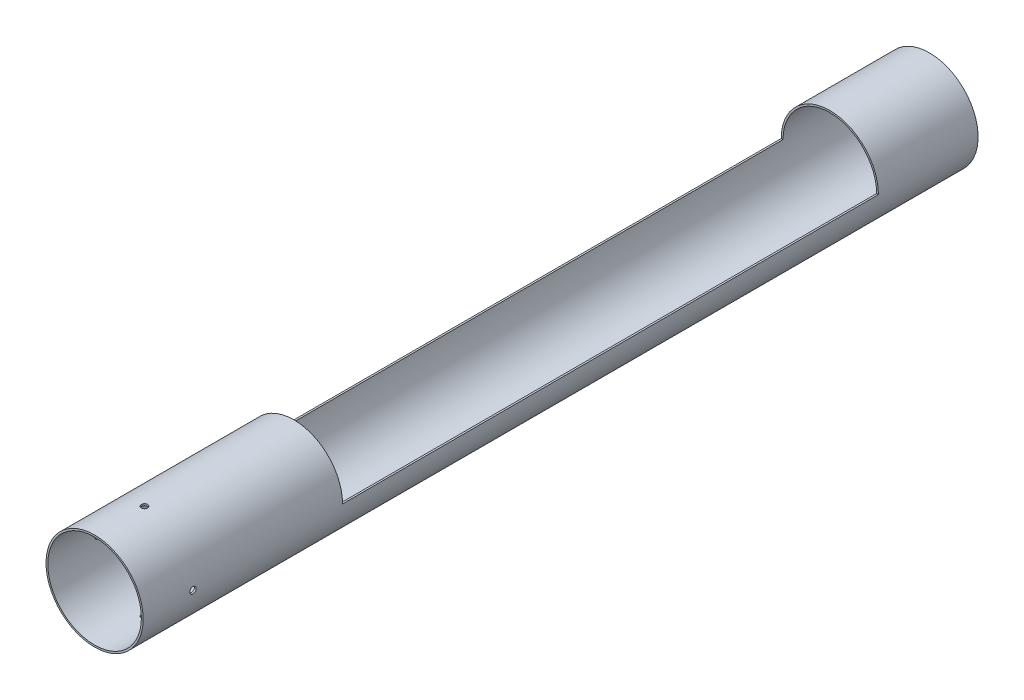
from build123d import *

# Parameters (mm, degrees)
BOSS_EXTRUDE1_DEPTH = 546.1
SKETCH2_R           = 49.5046
SKETCH2_R_2         = 47.6885
BOSS_EXTRUDE2_DEPTH = 203.2
BOSS_EXTRUDE3_START = 101.6
SKETCH3_R           = 49.5046
SKETCH3_R_2         = 47.6885
BOSS_EXTRUDE3_DEPTH = 101.6
SKETCH4_R           = 3.175
CUT_EXTRUDE1_DEPTH  = 753.563552693
CIRPATTERN1_COUNT   = 4


with BuildPart() as part:
    # Sketch1 → Boss-Extrude1 (new body)
    with BuildSketch(Plane.XY):
        with BuildLine():
            Line((-49.5046, 0), (-47.6885, 0))
            ThreePointArc((-47.6885, 0), (0, -47.6885), (47.6885, 0))
            Line((47.6885, 0), (49.5046, 0))
            ThreePointArc((49.5046, 0), (0, -49.5046), (-49.5046, 0))
        make_face()
    extrude(amount=BOSS_EXTRUDE1_DEPTH)

    # Sketch2 → Boss-Extrude2 (add)
    with BuildSketch(Plane.XY.offset(546.1)):
        Circle(SKETCH2_R)
        Circle(SKETCH2_R_2, mode=Mode.SUBTRACT)
    extrude(amount=BOSS_EXTRUDE2_DEPTH)

    # Sketch3 → Boss-Extrude3 (add)
    with BuildSketch(Plane(origin=(0, 0, 0), x_dir=(-1, 0, 0), z_dir=(0, 0, -1)).offset(BOSS_EXTRUDE3_START)):
        Circle(SKETCH3_R)
        Circle(SKETCH3_R_2, mode=Mode.SUBTRACT)
    extrude(amount=-BOSS_EXTRUDE3_DEPTH)

    # Sketch4 → Cut-Extrude1 (cut, through all)
    with BuildSketch(Plane(origin=(0, 0, 0), x_dir=(1, 0, 0), z_dir=(0, 1, 0))):
        with Locations(Location((0, -698.5, 0), (0, 0, 270))):
            Circle(SKETCH4_R)
    cut_extrude1 = extrude(amount=-CUT_EXTRUDE1_DEPTH, mode=Mode.SUBTRACT)

    # CirPattern1: Cut-Extrude1 ×4 about axis
    cirpattern1_axis = Axis((0, 0, 546.1), (0, 0, -1))
    for i in range(1, CIRPATTERN1_COUNT):
        add(cut_extrude1.rotate(cirpattern1_axis, i * 360 / CIRPATTERN1_COUNT), mode=Mode.SUBTRACT)


solid = part.part
